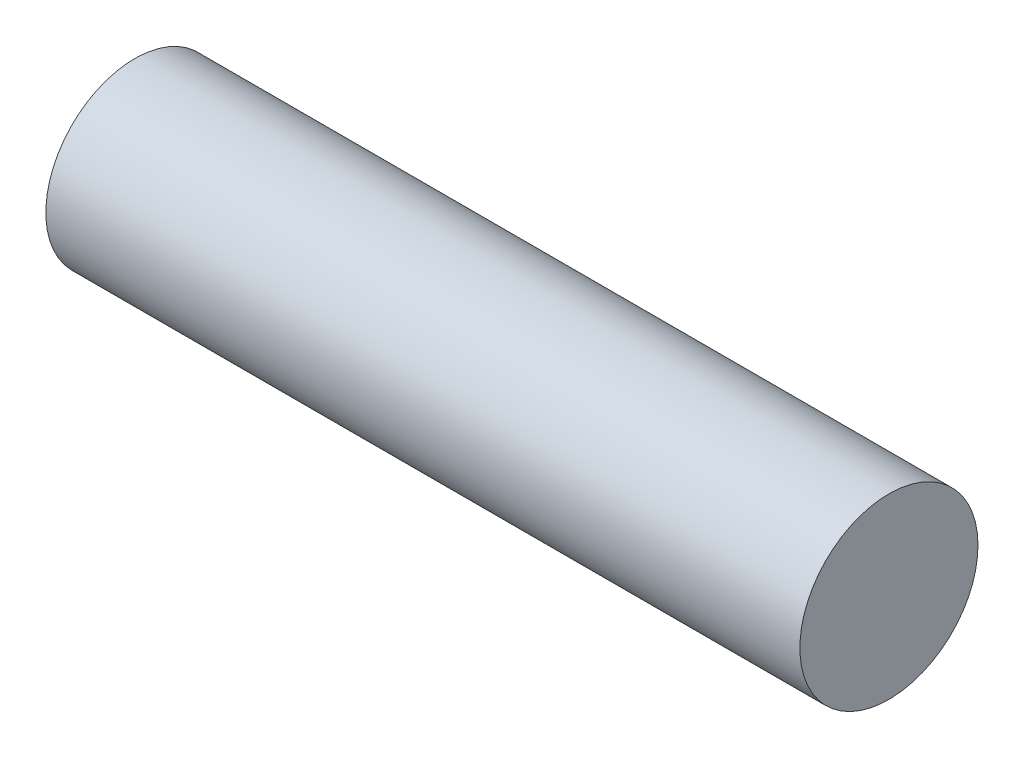
from build123d import *

# Parameters (mm, degrees)
SKETCH1_R           = 6
BOSS_EXTRUDE1_DEPTH = 50.8


with BuildPart() as part:
    # Sketch1 → Boss-Extrude1 (new body)
    with BuildSketch(Plane(origin=(0, 0, 0), x_dir=(0, 0, -1), z_dir=(1, 0, 0))):
        Circle(SKETCH1_R)
    extrude(amount=-BOSS_EXTRUDE1_DEPTH)


solid = part.part
